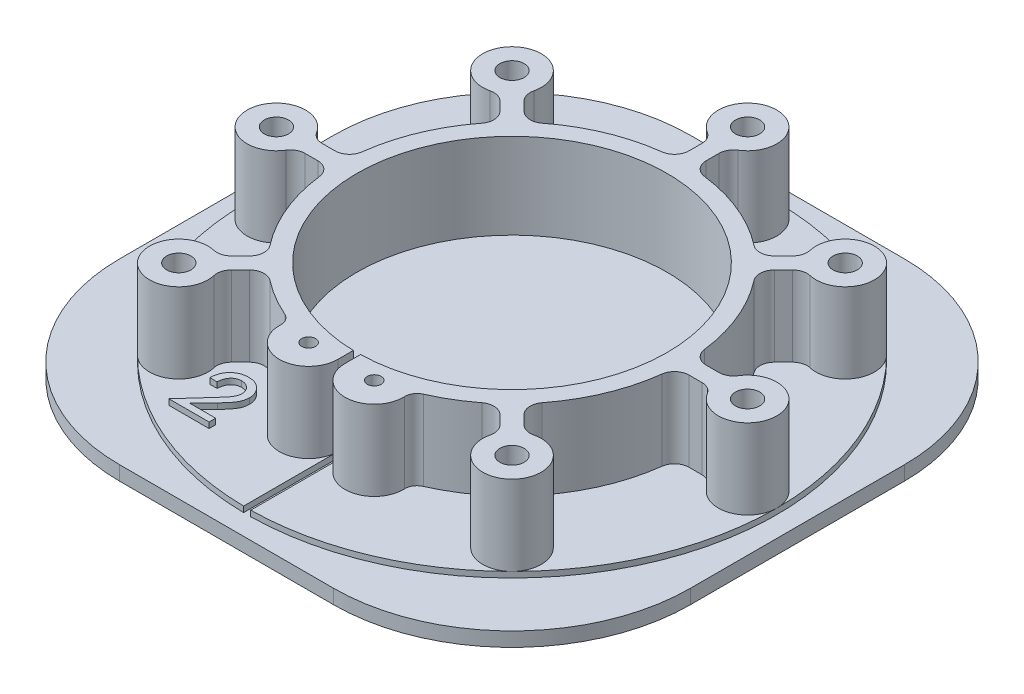
from build123d import *

# Parameters (mm, degrees)
SKETCH1_W           = 80
SKETCH1_H           = 80
BOSS_EXTRUDE1_DEPTH = 2
SKETCH2_R           = 1.7
SKETCH2_R_2         = 0.96852
BOSS_EXTRUDE2_DEPTH = 12
SKETCH3_R           = 1.4
CUT_EXTRUDE1_DEPTH  = 3
FILLET1_R           = 25
SKETCH5_R           = 37.128313
SKETCH5_R_2         = 1.7
SKETCH5_R_3         = 21.75
BOSS_EXTRUDE3_DEPTH = 0.8
SKETCH6_W           = 1
SKETCH6_H           = 15.384061
CUT_EXTRUDE2_DEPTH  = 3.8
BOSS_EXTRUDE4_DEPTH = 0.8


with BuildPart() as part:
    # Sketch1 → Boss-Extrude1 (new body)
    with BuildSketch(Plane(origin=(0, -11, 0), x_dir=(-1, 0, 0), z_dir=(0, -1, 0))):
        Rectangle(SKETCH1_W, SKETCH1_H)
    extrude(amount=BOSS_EXTRUDE1_DEPTH)

    # Sketch3 → Cut-Extrude1 (cut, through all)
    with BuildSketch(Plane(origin=(0, -11, 0), x_dir=(1, 0, 0), z_dir=(0, 1, 0))):
        with Locations((0, 33.028313)):
            Circle(SKETCH3_R)
        with Locations((23.354544, 23.354544)):
            Circle(SKETCH3_R)
        with Locations((33.028313, 0)):
            Circle(SKETCH3_R)
        with Locations((23.354544, -23.354544)):
            Circle(SKETCH3_R)
        with Locations((4.6, -23.911556)):
            Circle(SKETCH3_R)
        with Locations((-4.6, -23.911556)):
            Circle(SKETCH3_R)
        with Locations((-23.354544, -23.354544)):
            Circle(SKETCH3_R)
        with Locations((-33.028313, 0)):
            Circle(SKETCH3_R)
        with Locations((-23.354544, 23.354544)):
            Circle(SKETCH3_R)
    extrude(amount=-CUT_EXTRUDE1_DEPTH, mode=Mode.SUBTRACT)

    # Fillet1
    fillet1_edges = [part.edges().sort_by_distance(p)[0] for p in [
        (-40, -12, 40),
        (40, -12, 40),
        (40, -12, -40),
        (-40, -12, -40),
    ]]
    fillet(fillet1_edges, radius=FILLET1_R)


with BuildPart() as body_2:
    # Sketch2 → Boss-Extrude2 (new body)
    with BuildSketch(Plane(origin=(0, -11, 0), x_dir=(1, 0, 0), z_dir=(0, 1, 0))):
        with BuildLine():
            Line((-0.5, -21.744252), (-0.5, -23.911556))
            ThreePointArc((-0.5, -23.911556), (-4.675806, -28.010855), (-8.697197, -23.75997))
            ThreePointArc((-8.697197, -23.75997), (-8.955629, -22.794812), (-9.712074, -22.142043))
            ThreePointArc((-9.712074, -22.142043), (-12.375069, -20.771426), (-14.848178, -19.082088))
            ThreePointArc((-14.848178, -19.082088), (-16.232461, -18.654496), (-17.553147, -19.250203))
            Line((-17.553147, -19.250203), (-18.815181, -20.512237))
            ThreePointArc((-18.815181, -20.512237), (-19.336074, -21.397533), (-19.361448, -22.424391))
            ThreePointArc((-19.361448, -22.424391), (-26.253682, -26.253682), (-22.424391, -19.361448))
            ThreePointArc((-22.424391, -19.361448), (-21.397533, -19.336074), (-20.512237, -18.815181))
            Line((-20.512237, -18.815181), (-19.250203, -17.553147))
            ThreePointArc((-19.250203, -17.553147), (-18.654496, -16.232461), (-19.082088, -14.848178))
            ThreePointArc((-19.082088, -14.848178), (-22.337918, -9.252669), (-23.992321, -2.993827))
            ThreePointArc((-23.992321, -2.993827), (-24.668804, -1.712637), (-26.023898, -1.2))
            Line((-26.023898, -1.2), (-27.808684, -1.2))
            ThreePointArc((-27.808684, -1.2), (-28.80301, -1.457672), (-29.54705, -2.165828))
            ThreePointArc((-29.54705, -2.165828), (-37.128313, 0), (-29.54705, 2.165828))
            ThreePointArc((-29.54705, 2.165828), (-28.80301, 1.457672), (-27.808684, 1.2))
            Line((-27.808684, 1.2), (-26.023898, 1.2))
            ThreePointArc((-26.023898, 1.2), (-24.668804, 1.712637), (-23.992321, 2.993827))
            ThreePointArc((-23.992321, 2.993827), (-22.337918, 9.252669), (-19.082088, 14.848178))
            ThreePointArc((-19.082088, 14.848178), (-18.654496, 16.232461), (-19.250203, 17.553147))
            Line((-19.250203, 17.553147), (-20.512237, 18.815181))
            ThreePointArc((-20.512237, 18.815181), (-21.397533, 19.336074), (-22.424391, 19.361448))
            ThreePointArc((-22.424391, 19.361448), (-26.253682, 26.253682), (-19.361448, 22.424391))
            ThreePointArc((-19.361448, 22.424391), (-19.336074, 21.397533), (-18.815181, 20.512237))
            Line((-18.815181, 20.512237), (-17.553147, 19.250203))
            ThreePointArc((-17.553147, 19.250203), (-16.232461, 18.654496), (-14.848178, 19.082088))
            ThreePointArc((-14.848178, 19.082088), (-9.252669, 22.337918), (-2.993827, 23.992321))
            ThreePointArc((-2.993827, 23.992321), (-1.712637, 24.668804), (-1.2, 26.023898))
            Line((-1.2, 26.023898), (-1.2, 27.808684))
            ThreePointArc((-1.2, 27.808684), (-1.457672, 28.80301), (-2.165828, 29.54705))
            ThreePointArc((-2.165828, 29.54705), (0, 37.128313), (2.165828, 29.54705))
            ThreePointArc((2.165828, 29.54705), (1.457672, 28.80301), (1.2, 27.808684))
            Line((1.2, 27.808684), (1.2, 26.023898))
            ThreePointArc((1.2, 26.023898), (1.712637, 24.668804), (2.993827, 23.992321))
            ThreePointArc((2.993827, 23.992321), (9.252669, 22.337918), (14.848178, 19.082088))
            ThreePointArc((14.848178, 19.082088), (16.232461, 18.654496), (17.553147, 19.250203))
            Line((17.553147, 19.250203), (18.815181, 20.512237))
            ThreePointArc((18.815181, 20.512237), (19.336074, 21.397533), (19.361448, 22.424391))
            ThreePointArc((19.361448, 22.424391), (26.253682, 26.253682), (22.424391, 19.361448))
            ThreePointArc((22.424391, 19.361448), (21.397533, 19.336074), (20.512237, 18.815181))
            Line((20.512237, 18.815181), (19.250203, 17.553147))
            ThreePointArc((19.250203, 17.553147), (18.654496, 16.232461), (19.082088, 14.848178))
            ThreePointArc((19.082088, 14.848178), (22.337918, 9.252669), (23.992321, 2.993827))
            ThreePointArc((23.992321, 2.993827), (24.668804, 1.712637), (26.023898, 1.2))
            Line((26.023898, 1.2), (27.808684, 1.2))
            ThreePointArc((27.808684, 1.2), (28.80301, 1.457672), (29.54705, 2.165828))
            ThreePointArc((29.54705, 2.165828), (37.128313, 0), (29.54705, -2.165828))
            ThreePointArc((29.54705, -2.165828), (28.80301, -1.457672), (27.808684, -1.2))
            Line((27.808684, -1.2), (26.023898, -1.2))
            ThreePointArc((26.023898, -1.2), (24.668804, -1.712637), (23.992321, -2.993827))
            ThreePointArc((23.992321, -2.993827), (22.337918, -9.252669), (19.082088, -14.848178))
            ThreePointArc((19.082088, -14.848178), (18.654496, -16.232461), (19.250203, -17.553147))
            Line((19.250203, -17.553147), (20.512237, -18.815181))
            ThreePointArc((20.512237, -18.815181), (21.397533, -19.336074), (22.424391, -19.361448))
            ThreePointArc((22.424391, -19.361448), (26.253682, -26.253682), (19.361448, -22.424391))
            ThreePointArc((19.361448, -22.424391), (19.336074, -21.397533), (18.815181, -20.512237))
            Line((18.815181, -20.512237), (17.553147, -19.250203))
            ThreePointArc((17.553147, -19.250203), (16.232461, -18.654496), (14.848178, -19.082088))
            ThreePointArc((14.848178, -19.082088), (12.375069, -20.771426), (9.712074, -22.142043))
            ThreePointArc((9.712074, -22.142043), (8.955629, -22.794812), (8.697197, -23.75997))
            ThreePointArc((8.697197, -23.75997), (4.675806, -28.010855), (0.5, -23.911556))
            Line((0.5, -23.911556), (0.5, -21.744252))
            ThreePointArc((0.5, -21.744252), (0, 21.75), (-0.5, -21.744252))
        make_face()
        with Locations((0, 33.028313)):
            Circle(SKETCH2_R, mode=Mode.SUBTRACT)
        with Locations((-23.354544, 23.354544)):
            Circle(SKETCH2_R, mode=Mode.SUBTRACT)
        with Locations((-33.028313, 0)):
            Circle(SKETCH2_R, mode=Mode.SUBTRACT)
        with Locations((-23.354544, -23.354544)):
            Circle(SKETCH2_R, mode=Mode.SUBTRACT)
        with Locations((33.028313, 0)):
            Circle(SKETCH2_R, mode=Mode.SUBTRACT)
        with Locations((23.354544, 23.354544)):
            Circle(SKETCH2_R, mode=Mode.SUBTRACT)
        with Locations((23.354544, -23.354544)):
            Circle(SKETCH2_R, mode=Mode.SUBTRACT)
        with Locations((-4.6, -23.911556)):
            Circle(SKETCH2_R_2, mode=Mode.SUBTRACT)
        with Locations((4.6, -23.911556)):
            Circle(SKETCH2_R_2, mode=Mode.SUBTRACT)
    extrude(amount=BOSS_EXTRUDE2_DEPTH)

    # Sketch5 → Boss-Extrude3 (add)
    with BuildSketch(Plane.XZ.offset(11)):
        Circle(SKETCH5_R)
        with Locations((-23.354544, 23.354544)):
            Circle(SKETCH5_R_2, mode=Mode.SUBTRACT)
        with Locations((-4.6, 23.911556)):
            Circle(SKETCH5_R_2, mode=Mode.SUBTRACT)
        with Locations((4.6, 23.911556)):
            Circle(SKETCH5_R_2, mode=Mode.SUBTRACT)
        with Locations((23.354544, 23.354544)):
            Circle(SKETCH5_R_2, mode=Mode.SUBTRACT)
        with Locations((33.028313, 0)):
            Circle(SKETCH5_R_2, mode=Mode.SUBTRACT)
        with Locations((23.354544, -23.354544)):
            Circle(SKETCH5_R_2, mode=Mode.SUBTRACT)
        with Locations((0, -33.028313)):
            Circle(SKETCH5_R_2, mode=Mode.SUBTRACT)
        with Locations((-23.354544, -23.354544)):
            Circle(SKETCH5_R_2, mode=Mode.SUBTRACT)
        with Locations((-33.028313, 0)):
            Circle(SKETCH5_R_2, mode=Mode.SUBTRACT)
        Circle(SKETCH5_R_3, mode=Mode.SUBTRACT)
    extrude(amount=-BOSS_EXTRUDE3_DEPTH)

    # Sketch6 → Cut-Extrude2 (cut, through all)
    with BuildSketch(Plane(origin=(0, -10.2, 0), x_dir=(1, 0, 0), z_dir=(0, 1, 0))):
        with Locations((0, -29.436282)):
            Rectangle(SKETCH6_W, SKETCH6_H)
    extrude(amount=-CUT_EXTRUDE2_DEPTH, mode=Mode.SUBTRACT)

    # Sketch7 → Boss-Extrude4 (add)
    with BuildSketch(Plane(origin=(0, -10.2, 0), x_dir=(1, 0, 0), z_dir=(0, 1, 0))):
        with BuildLine():
            Line((-16.64582, -24.702466), (-17.660243, -24.702466))
            add(Edge.make_bspline(
                [(-17.660243, -24.702466), (-17.655478, -24.599243), (-17.646158, -24.397353), (-17.604773, -24.103176), (-17.537733, -23.825987), (-17.453114, -23.563435), (-17.340235, -23.318803), (-17.209995, -23.087825), (-17.052765, -22.875344), (-16.875087, -22.681021), (-16.682211, -22.504472), (-16.474869, -22.352237), (-16.256565, -22.22251), (-16.027255, -22.116652), (-15.786493, -22.034688), (-15.534962, -21.975045), (-15.271861, -21.939171), (-15.092512, -21.935232), (-15.001589, -21.933235)],
                knots=[0, 0, 0, 0, 0.00031, 0.000606, 0.000889, 0.001165, 0.001432, 0.001696, 0.001959, 0.002223, 0.002485, 0.002742, 0.002993, 0.003246, 0.003498, 0.003755, 0.00402, 0.004293, 0.004293, 0.004293, 0.004293], degree=3))
            add(Edge.make_bspline(
                [(-15.001589, -21.933235), (-14.906392, -21.935182), (-14.719588, -21.939003), (-14.447558, -21.974961), (-14.190105, -22.032943), (-13.947156, -22.112126), (-13.719153, -22.217855), (-13.505646, -22.345353), (-13.308688, -22.498601), (-13.126848, -22.670076), (-12.966237, -22.858699), (-12.821172, -23.052627), (-12.701262, -23.255791), (-12.600808, -23.464483), (-12.523506, -23.680415), (-12.468916, -23.902707), (-12.436194, -24.131512), (-12.431728, -24.286228), (-12.429473, -24.364325)],
                knots=[0, 0, 0, 0, 0.000285, 0.00056, 0.000821, 0.001076, 0.001325, 0.001574, 0.001821, 0.002072, 0.002322, 0.002563, 0.002798, 0.003029, 0.003257, 0.003485, 0.003715, 0.003949, 0.003949, 0.003949, 0.003949], degree=3))
            add(Edge.make_bspline(
                [(-12.429473, -24.364325), (-12.433576, -24.473569), (-12.441724, -24.690562), (-12.504471, -25.01159), (-12.609956, -25.322278), (-12.731801, -25.575259), (-12.855033, -25.779748), (-12.968121, -25.948535), (-13.100971, -26.131045), (-13.256432, -26.326056), (-13.428321, -26.53803), (-13.623466, -26.7615), (-13.835829, -27.000988), (-13.987282, -27.162248), (-14.065691, -27.245735)],
                knots=[0, 0, 0, 0, 0.000328, 0.000651, 0.000977, 0.00131, 0.001491, 0.001693, 0.001919, 0.002168, 0.002441, 0.002738, 0.003058, 0.003401, 0.003401, 0.003401, 0.003401], degree=3))
            Line((-14.065691, -27.245735), (-16.03364, -29.215286))
            Line((-16.03364, -29.215286), (-12.326909, -29.215286))
            Line((-12.326909, -29.215286), (-12.326909, -30.138363))
            Line((-12.326909, -30.138363), (-17.967935, -30.138363))
            Line((-17.967935, -30.138363), (-14.907037, -26.758555))
            add(Edge.make_bspline(
                [(-14.907037, -26.758555), (-14.834131, -26.680801), (-14.694222, -26.53159), (-14.49704, -26.313169), (-14.319138, -26.111241), (-14.159567, -25.925954), (-14.022506, -25.754817), (-13.904267, -25.600346), (-13.806189, -25.461814), (-13.704335, -25.298749), (-13.603408, -25.10328), (-13.517551, -24.864834), (-13.466033, -24.621329), (-13.458756, -24.457511), (-13.455114, -24.375543)],
                knots=[0, 0, 0, 0, 0.00032, 0.000614, 0.000883, 0.001127, 0.001347, 0.00154, 0.001711, 0.001856, 0.002117, 0.002369, 0.002614, 0.00286, 0.00286, 0.00286, 0.00286], degree=3))
            add(Edge.make_bspline(
                [(-13.455114, -24.375543), (-13.456012, -24.324692), (-13.457787, -24.224074), (-13.481995, -24.076732), (-13.516096, -23.933817), (-13.568838, -23.797629), (-13.632383, -23.665488), (-13.711866, -23.539101), (-13.807311, -23.419642), (-13.913485, -23.304423), (-14.030916, -23.200392), (-14.154951, -23.107093), (-14.287116, -23.031321), (-14.423797, -22.965057), (-14.569242, -22.918081), (-14.719877, -22.883104), (-14.876884, -22.858875), (-14.983867, -22.857178), (-15.038448, -22.856312)],
                knots=[0, 0, 0, 0, 0.000152, 0.000302, 0.000447, 0.000592, 0.000739, 0.000886, 0.001039, 0.001197, 0.001356, 0.001509, 0.001662, 0.001812, 0.001964, 0.002119, 0.002276, 0.002439, 0.002439, 0.002439, 0.002439], degree=3))
            add(Edge.make_bspline(
                [(-15.038448, -22.856312), (-15.090337, -22.857376), (-15.192417, -22.85947), (-15.342756, -22.881072), (-15.487062, -22.916244), (-15.625823, -22.965031), (-15.760043, -23.02522), (-15.886441, -23.103195), (-16.007083, -23.193904), (-16.123564, -23.295711), (-16.229575, -23.415151), (-16.324393, -23.550809), (-16.408122, -23.702831), (-16.47969, -23.870954), (-16.539001, -24.055616), (-16.58658, -24.256595), (-16.623364, -24.473977), (-16.638196, -24.624894), (-16.64582, -24.702466)],
                knots=[0, 0, 0, 0, 0.000156, 0.000306, 0.000455, 0.000601, 0.000747, 0.000895, 0.001045, 0.001199, 0.001358, 0.001523, 0.001695, 0.001878, 0.00207, 0.002276, 0.002497, 0.002731, 0.002731, 0.002731, 0.002731], degree=3))
        make_face()
    extrude(amount=BOSS_EXTRUDE4_DEPTH)


solid = Compound([part.part, body_2.part])
